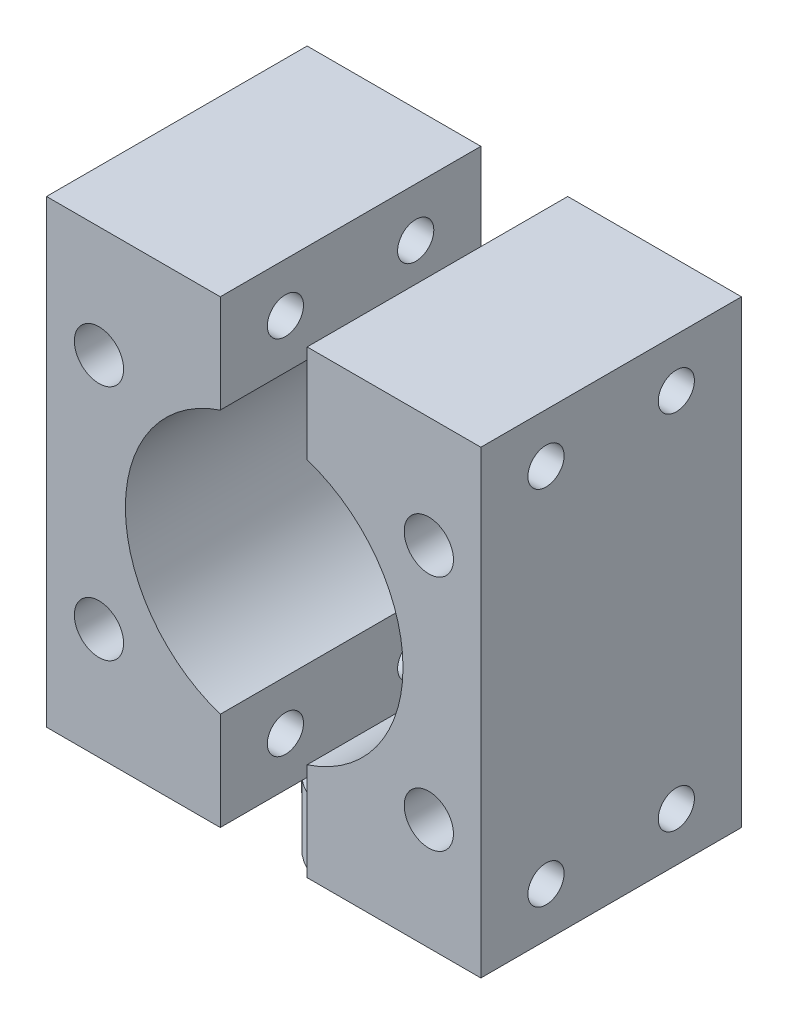
from build123d import *

# Parameters (mm, degrees)
SKETCH2_W             = 12
SKETCH2_H             = 18
EXTRUDE1_DEPTH        = 31.75
EXTRUDE1_2_DEPTH      = 31.75
EXTRUDE2_DEPTH        = 4.5
SKETCH4_R             = 9.5885
EXTRUDE3_DEPTH        = 17
M3X0_5_TAPPED_HOLE1_D = 2.5
M3_CLEARANCE_HOLE1_D  = 3.4


with BuildPart() as part:
    # Sketch2 → Extrude1 (new body)
    with BuildSketch(Plane(origin=(0, 4.5, 0), x_dir=(-1, 0, 0), z_dir=(0, 1, 0))):
        with Locations((9, 0.343878918)):
            Rectangle(SKETCH2_W, SKETCH2_H)
    extrude(amount=EXTRUDE1_DEPTH)



with BuildPart() as body_2:
    # Sketch2 → Extrude1 2 (new body)
    with BuildSketch(Plane(origin=(0, 4.5, 0), x_dir=(-1, 0, 0), z_dir=(0, 1, 0))):
        with Locations((-9, 0.343878918)):
            Rectangle(SKETCH2_W, SKETCH2_H)
    extrude(amount=EXTRUDE1_2_DEPTH)


with BuildPart() as part_1:
    add(part.part)

    add(body_2.part)  # Extrude2 merges body 2
    # Sketch1 → Extrude2 (add)
    with BuildSketch(Plane(origin=(0, 0, 0), x_dir=(1, 0, 0), z_dir=(0, 1, 0))):
        with BuildLine():
            ThreePointArc((4.75, 0), (3.852758752, 2.778263846), (1.5, 4.506939094))
            Line((1.5, 4.506939094), (1.5, -4.506939094))
            ThreePointArc((1.5, -4.506939094), (3.852758752, -2.778263846), (4.75, 0))
        make_face()
        with BuildLine():
            Line((-1.5, -4.506939094), (-1.5, 4.506939094))
            ThreePointArc((-1.5, 4.506939094), (-4.75, 0), (-1.5, -4.506939094))
        make_face()
    extrude(amount=EXTRUDE2_DEPTH)

    # Sketch4 → Extrude3 (cut)
    with BuildSketch(Plane.XY.offset(9.343878918)):
        with Locations((0.033766691, 20.375)):
            Circle(SKETCH4_R)
    extrude(amount=-EXTRUDE3_DEPTH, mode=Mode.SUBTRACT)

    # M3x0.5 Tapped Hole1 (through all)
    with Locations(Plane(origin=(15, 32.871578641, 4.843878918), x_dir=(0, 0, 1), z_dir=(1, 0, 0))):
        with Locations((0, 0), (-9, 0), (0, 24.993157282), (-9, 24.993157282)):
            Hole(M3X0_5_TAPPED_HOLE1_D / 2)

    # M3 Clearance Hole1 (through all)
    with Locations(Plane(origin=(-11.377218639, 28.569859147, 9.343878918), x_dir=(1, 0, 0), z_dir=(0, 0, 1))):
        with Locations((0, 0), (0, -16.389718294), (22.782225349, -16.398024537), (22.782225349, 0.008306243)):
            Hole(M3_CLEARANCE_HOLE1_D / 2)


solid = part_1.part
